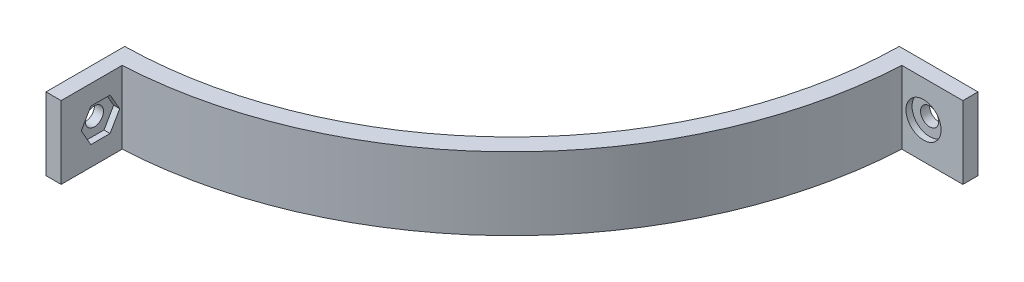
from build123d import *

# Parameters (mm, degrees)
SKETCH1_R                   = 68
SKETCH1_R_2                 = 65
BOSS_EXTRUDE1_DEPTH         = 25
BOSS_EXTRUDE2_START         = -0.090133
SKETCH2_W                   = 7
SKETCH2_H                   = 50
BOSS_EXTRUDE2_DEPTH         = 10.090133
SKETCH3_W                   = 2
SKETCH3_H                   = 50
CUT_EXTRUDE1_DEPTH          = 10
CIRPATTERN2_COUNT           = 4
SKETCH7_R                   = 2.9
CUT_EXTRUDE4_DEPTH          = 1
CUT_EXTRUDE5_DEPTH          = 1
SKETCH9_R                   = 1.5
CUT_EXTRUDE6_DEPTH          = 115.844460032
CIRPATTERN3_COUNT           = 4
CIRPATTERN3_COPY_1_SKETCH_R = 2.9
CIRPATTERN3_COPY_1_DEPTH    = 1
CIRPATTERN3_COPY_2_SKETCH_R = 2.9
CIRPATTERN3_COPY_2_DEPTH    = 1
CIRPATTERN3_COPY_3_SKETCH_R = 2.9
CIRPATTERN3_COPY_3_DEPTH    = 1
CIRPATTERN3_COPY_4_DEPTH    = 1
CIRPATTERN3_COPY_5_DEPTH    = 1
CIRPATTERN3_COPY_6_DEPTH    = 1
CIRPATTERN3_COPY_7_SKETCH_R = 1.5
CIRPATTERN3_COPY_7_DEPTH    = 115.844460032
CIRPATTERN3_COPY_8_SKETCH_R = 1.5
CIRPATTERN3_COPY_8_DEPTH    = 115.844460032
CIRPATTERN3_COPY_9_SKETCH_R = 1.5
CIRPATTERN3_COPY_9_DEPTH    = 115.844460032
SKETCH10_W                  = 172.322225858
SKETCH10_H                  = 181.395343574
CUT_EXTRUDE7_DEPTH          = 13
CUT_EXTRUDE7_DEPTH_BACK     = 114.106144837
SKETCH4_W                   = 204.796424039
SKETCH4_H                   = 80.613482063
CUT_EXTRUDE2_DEPTH          = 114.106144837
SKETCH5_W                   = 133.005640426
SKETCH5_H                   = 101.362408315
CUT_EXTRUDE3_DEPTH          = 114.106144837
SKETCH11_W                  = 1
SKETCH11_H                  = 12
CUT_EXTRUDE8_DEPTH          = 107.456563912
CUT_EXTRUDE8_DEPTH_BACK     = 107.456563912
SKETCH12_W                  = 1
SKETCH12_H                  = 12
CUT_EXTRUDE9_DEPTH          = 10


with BuildPart() as part:
    # Sketch1 → Boss-Extrude1 (new, symmetric)
    with BuildSketch(Plane(origin=(0, 0, 0), x_dir=(1, 0, 0), z_dir=(0, 1, 0))):
        with Locations(Location((0, 0, 0), (0, 0, 270))):
            Circle(SKETCH1_R)
        with Locations(Location((0, 0, 0), (0, 0, 270))):
            Circle(SKETCH1_R_2, mode=Mode.SUBTRACT)
    extrude(amount=BOSS_EXTRUDE1_DEPTH, both=True)

    # Sketch2 → Boss-Extrude2 (add)
    with BuildSketch(Plane(origin=(68, 0, 0), x_dir=(0, 0, -1), z_dir=(1, 0, 0)).offset(BOSS_EXTRUDE2_START)):
        Rectangle(SKETCH2_W, SKETCH2_H)
    boss_extrude2 = extrude(amount=BOSS_EXTRUDE2_DEPTH)

    # Sketch3 → Cut-Extrude1 (cut)
    with BuildSketch(Plane(origin=(78, 0, 0), x_dir=(0, 0, -1), z_dir=(1, 0, 0))):
        Rectangle(SKETCH3_W, SKETCH3_H)
    cut_extrude1 = extrude(amount=-CUT_EXTRUDE1_DEPTH, mode=Mode.SUBTRACT)

    # CirPattern2: Boss-Extrude2, Cut-Extrude1 ×4 about axis
    cirpattern2_axis = Axis((0, 0, 0), (0, 1, 0))
    add([boss_extrude2.rotate(cirpattern2_axis, i * 360 / CIRPATTERN2_COUNT) for i in range(1, CIRPATTERN2_COUNT)])
    add([cut_extrude1.rotate(cirpattern2_axis, i * 360 / CIRPATTERN2_COUNT) for i in range(1, CIRPATTERN2_COUNT)], mode=Mode.SUBTRACT)

    # Sketch7 → Cut-Extrude4 (cut)
    with BuildSketch(Plane.XY.offset(3.5)):
        with Locations((71.5, 19)):
            Circle(SKETCH7_R)
    cut_extrude4 = extrude(amount=-CUT_EXTRUDE4_DEPTH, mode=Mode.SUBTRACT)

    # Sketch8 → Cut-Extrude5 (cut)
    with BuildSketch(Plane(origin=(0, 0, -3.5), x_dir=(-1, 0, 0), z_dir=(0, 0, -1))):
        Polygon((-69.91228676, 16.25), (-68.324573519, 19), (-69.91228676, 21.75), (-73.08771324, 21.75), (-74.675426481, 19), (-73.08771324, 16.25), align=None)
    cut_extrude5 = extrude(amount=-CUT_EXTRUDE5_DEPTH, mode=Mode.SUBTRACT)

    # Sketch9 → Cut-Extrude6 (cut, through all)
    with BuildSketch(Plane.XY.offset(2.5)):
        with Locations((71.5, 19)):
            Circle(SKETCH9_R)
    cut_extrude6 = extrude(amount=-CUT_EXTRUDE6_DEPTH, mode=Mode.SUBTRACT)

    # Mirror1: Cut-Extrude4, Cut-Extrude5, Cut-Extrude6 across plane
    add(cut_extrude4.mirror(Plane.ZX), mode=Mode.SUBTRACT)
    add(cut_extrude5.mirror(Plane.ZX), mode=Mode.SUBTRACT)
    add(cut_extrude6.mirror(Plane.ZX), mode=Mode.SUBTRACT)

    # CirPattern3: Cut-Extrude4, Cut-Extrude5, Cut-Extrude6 ×4 about axis
    cirpattern3_axis = Axis((0, 0, 0), (0, 1, 0))
    add([cut_extrude4.rotate(cirpattern3_axis, i * 360 / CIRPATTERN3_COUNT) for i in range(1, CIRPATTERN3_COUNT)], mode=Mode.SUBTRACT)
    add([cut_extrude5.rotate(cirpattern3_axis, i * 360 / CIRPATTERN3_COUNT) for i in range(1, CIRPATTERN3_COUNT)], mode=Mode.SUBTRACT)
    add([cut_extrude6.rotate(cirpattern3_axis, i * 360 / CIRPATTERN3_COUNT) for i in range(1, CIRPATTERN3_COUNT)], mode=Mode.SUBTRACT)

    # CirPattern3 copy 1 sketch → CirPattern3 copy 1 (cut)
    with BuildSketch(Plane(origin=(3.5, 0, 0), x_dir=(0, 0, -1), z_dir=(1, 0, 0))):
        with Locations((71.5, -19)):
            Circle(CIRPATTERN3_COPY_1_SKETCH_R)
    extrude(amount=-CIRPATTERN3_COPY_1_DEPTH, mode=Mode.SUBTRACT)

    # CirPattern3 copy 2 sketch → CirPattern3 copy 2 (cut)
    with BuildSketch(Plane(origin=(0, 0, -3.5), x_dir=(-1, 0, 0), z_dir=(0, 0, -1))):
        with Locations((71.5, -19)):
            Circle(CIRPATTERN3_COPY_2_SKETCH_R)
    extrude(amount=-CIRPATTERN3_COPY_2_DEPTH, mode=Mode.SUBTRACT)

    # CirPattern3 copy 3 sketch → CirPattern3 copy 3 (cut)
    with BuildSketch(Plane.ZY.offset(3.5)):
        with Locations((71.5, -19)):
            Circle(CIRPATTERN3_COPY_3_SKETCH_R)
    extrude(amount=-CIRPATTERN3_COPY_3_DEPTH, mode=Mode.SUBTRACT)

    # CirPattern3 copy 4 sketch → CirPattern3 copy 4 (cut)
    with BuildSketch(Plane.ZY.offset(3.5)):
        Polygon((-69.91228676, -16.25), (-68.324573519, -19), (-69.91228676, -21.75), (-73.08771324, -21.75), (-74.675426481, -19), (-73.08771324, -16.25), align=None)
    extrude(amount=-CIRPATTERN3_COPY_4_DEPTH, mode=Mode.SUBTRACT)

    # CirPattern3 copy 5 sketch → CirPattern3 copy 5 (cut)
    with BuildSketch(Plane.XY.offset(3.5)):
        Polygon((-69.91228676, -16.25), (-68.324573519, -19), (-69.91228676, -21.75), (-73.08771324, -21.75), (-74.675426481, -19), (-73.08771324, -16.25), align=None)
    extrude(amount=-CIRPATTERN3_COPY_5_DEPTH, mode=Mode.SUBTRACT)

    # CirPattern3 copy 6 sketch → CirPattern3 copy 6 (cut)
    with BuildSketch(Plane(origin=(3.5, 0, 0), x_dir=(0, 0, -1), z_dir=(1, 0, 0))):
        Polygon((-69.91228676, -16.25), (-68.324573519, -19), (-69.91228676, -21.75), (-73.08771324, -21.75), (-74.675426481, -19), (-73.08771324, -16.25), align=None)
    extrude(amount=-CIRPATTERN3_COPY_6_DEPTH, mode=Mode.SUBTRACT)

    # CirPattern3 copy 7 sketch → CirPattern3 copy 7 (cut, through all)
    with BuildSketch(Plane(origin=(2.5, 0, 0), x_dir=(0, 0, -1), z_dir=(1, 0, 0))):
        with Locations((71.5, -19)):
            Circle(CIRPATTERN3_COPY_7_SKETCH_R)
    extrude(amount=-CIRPATTERN3_COPY_7_DEPTH, mode=Mode.SUBTRACT)

    # CirPattern3 copy 8 sketch → CirPattern3 copy 8 (cut, through all)
    with BuildSketch(Plane(origin=(0, 0, -2.5), x_dir=(-1, 0, 0), z_dir=(0, 0, -1))):
        with Locations((71.5, -19)):
            Circle(CIRPATTERN3_COPY_8_SKETCH_R)
    extrude(amount=-CIRPATTERN3_COPY_8_DEPTH, mode=Mode.SUBTRACT)

    # CirPattern3 copy 9 sketch → CirPattern3 copy 9 (cut, through all)
    with BuildSketch(Plane.ZY.offset(2.5)):
        with Locations((71.5, -19)):
            Circle(CIRPATTERN3_COPY_9_SKETCH_R)
    extrude(amount=-CIRPATTERN3_COPY_9_DEPTH, mode=Mode.SUBTRACT)

    # Sketch10 → Cut-Extrude7 (cut, two sides)
    with BuildSketch(Plane(origin=(0, 0, 0), x_dir=(1, 0, 0), z_dir=(0, 1, 0))) as cut_extrude7_sk:
        with Locations((0.161152427, 1.352018999)):
            Rectangle(SKETCH10_W, SKETCH10_H)
    extrude(amount=CUT_EXTRUDE7_DEPTH, mode=Mode.SUBTRACT)
    extrude(cut_extrude7_sk.sketch, amount=-CUT_EXTRUDE7_DEPTH_BACK, mode=Mode.SUBTRACT)

    # Sketch4 → Cut-Extrude2 (cut, through all)
    with BuildSketch(Plane.XY):
        with Locations((-0.265516435, -0.614198292)):
            Rectangle(SKETCH4_W, SKETCH4_H)
    extrude(amount=-CUT_EXTRUDE2_DEPTH, mode=Mode.SUBTRACT)

    # Sketch5 → Cut-Extrude3 (cut, through all)
    with BuildSketch(Plane(origin=(0, 0, 0), x_dir=(0, 0, -1), z_dir=(1, 0, 0))):
        with Locations((-14.085466414, 0.839605882)):
            Rectangle(SKETCH5_W, SKETCH5_H)
    extrude(amount=-CUT_EXTRUDE3_DEPTH, mode=Mode.SUBTRACT)

    # Sketch11 → Cut-Extrude8 (cut, two sides)
    with BuildSketch(Plane(origin=(68, 0, 0), x_dir=(0, 0, -1), z_dir=(1, 0, 0))) as cut_extrude8_sk:
        with Locations((-0.5, 19)):
            Rectangle(SKETCH11_W, SKETCH11_H)
    extrude(amount=CUT_EXTRUDE8_DEPTH, mode=Mode.SUBTRACT)
    extrude(cut_extrude8_sk.sketch, amount=-CUT_EXTRUDE8_DEPTH_BACK, mode=Mode.SUBTRACT)

    # Sketch12 → Cut-Extrude9 (cut)
    with BuildSketch(Plane.XY.offset(68)):
        with Locations((0.5, 19)):
            Rectangle(SKETCH12_W, SKETCH12_H)
    extrude(amount=-CUT_EXTRUDE9_DEPTH, mode=Mode.SUBTRACT)


solid = part.part
